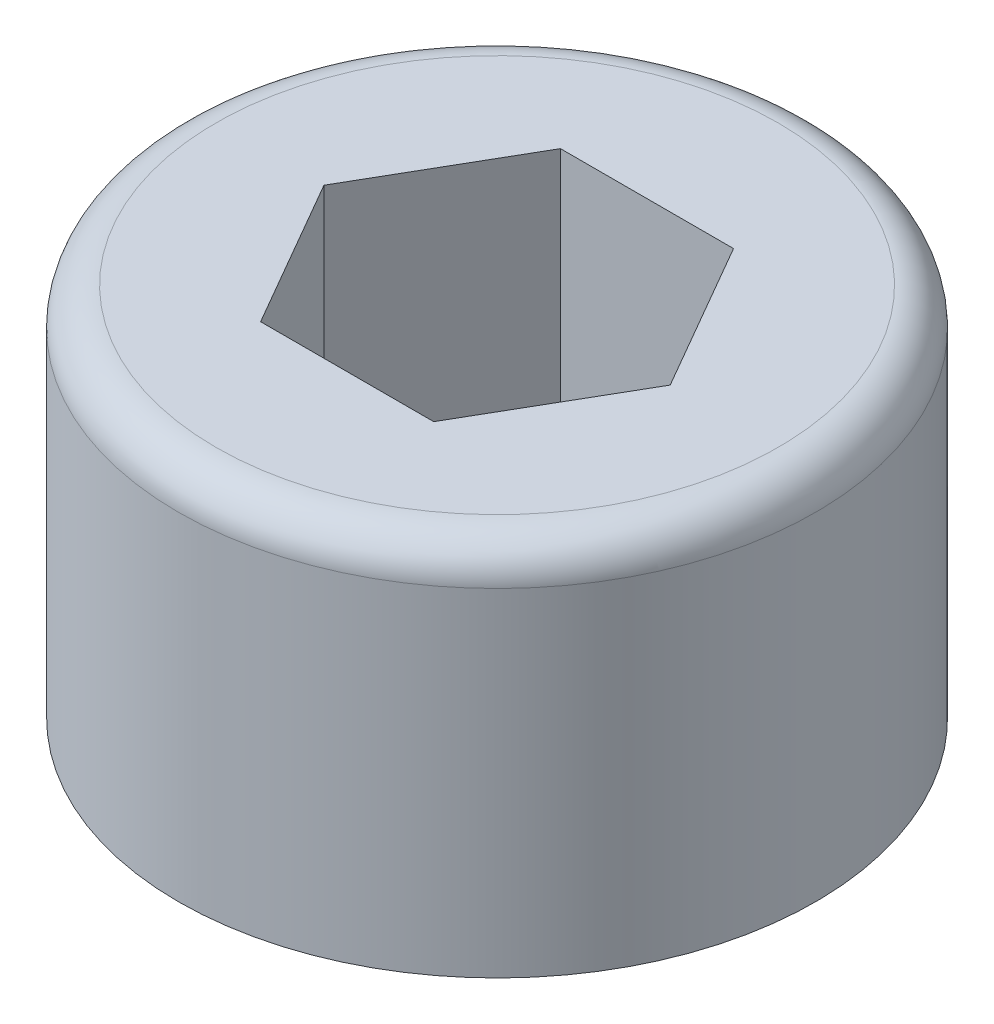
from build123d import *

# Parameters (mm, degrees)
SKETCH1_R           = 4.25
BOSS_EXTRUDE1_DEPTH = 5
CUT_EXTRUDE1_DEPTH  = 3
FILLET1_R           = 0.5


with BuildPart() as part:
    # Sketch1 → Boss-Extrude1 (new body)
    with BuildSketch(Plane(origin=(0, 0, 0), x_dir=(1, 0, 0), z_dir=(0, 1, 0))):
        Circle(SKETCH1_R)
    extrude(amount=BOSS_EXTRUDE1_DEPTH)

    # Sketch2 → Cut-Extrude1 (cut)
    with BuildSketch(Plane(origin=(0, 5, 0), x_dir=(1, 0, 0), z_dir=(0, 1, 0))):
        Polygon((-2.309401077, 0), (-1.154700538, -2), (1.154700538, -2), (2.309401077, 0), (1.154700538, 2), (-1.154700538, 2), align=None)
    extrude(amount=-CUT_EXTRUDE1_DEPTH, mode=Mode.SUBTRACT)

    # Fillet1
    fillet1_edges = [part.edges().sort_by_distance(p)[0] for p in [
        (-4.25, 5, 0),
    ]]
    fillet(fillet1_edges, radius=FILLET1_R)


solid = part.part
